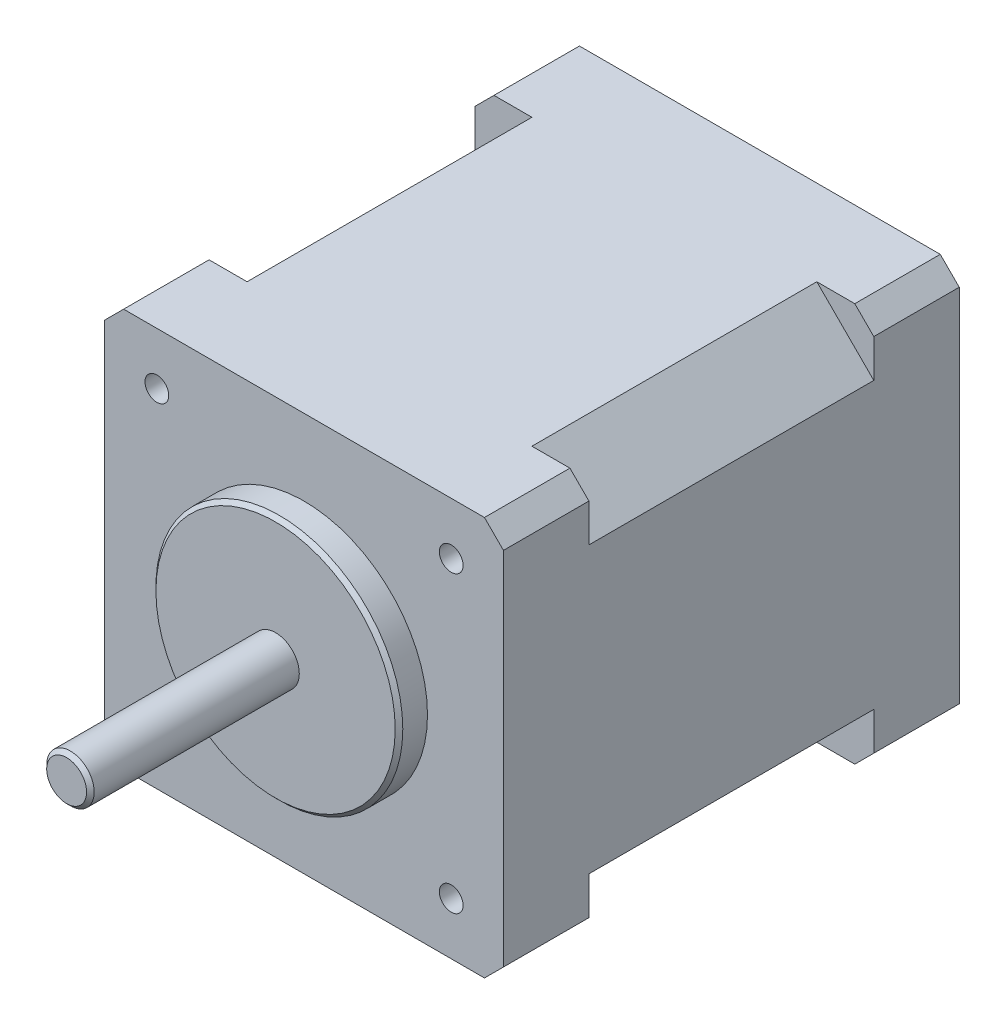
from build123d import *

# Parameters (mm, degrees)
ESQUISSE1_W                               = 42
ESQUISSE1_H                               = 42
BOSS_EXTRU_1_DEPTH                        = 48
CHANFREIN1_SIZE                           = 2
ESQUISSE3_R                               = 13
BOSS_EXTRU_2_DEPTH                        = 3
TROU_POUR_TARAUDAGE_POUR_TROU_TARAUD_M3_D = 2.5
ESQUISSE7_R                               = 2.5
BOSS_EXTRU_3_DEPTH                        = 22
CHANFREIN2_SIZE                           = 0.4
CHANFREIN3_SIZE                           = 0.4
ENL_V_START                               = -9
ENL_V_MAT_EXTRU_1_DEPTH                   = 30


with BuildPart() as part:
    # Esquisse1 → Boss.-Extru.1 (new body)
    with BuildSketch(Plane.XY):
        Rectangle(ESQUISSE1_W, ESQUISSE1_H)
    extrude(amount=BOSS_EXTRU_1_DEPTH)

    # Chanfrein1
    chanfrein1_edges = [part.edges().sort_by_distance(p)[0] for p in [
        (-21, 21, 24),
        (21, 21, 24),
        (21, -21, 24),
        (-21, -21, 24),
    ]]
    chamfer(chanfrein1_edges, length=CHANFREIN1_SIZE)

    # Esquisse3 → Boss.-Extru.2 (add)
    with BuildSketch(Plane.XY.offset(48)):
        Circle(ESQUISSE3_R)
    extrude(amount=BOSS_EXTRU_2_DEPTH)

    # Trou pour taraudage pour trou taraudé M3x0.51 (through all)
    with Locations(Plane.XY.offset(48)):
        with Locations((-15.5, 15.5), (-15.5, -15.5), (15.5, -15.5), (15.5, 15.5)):
            Hole(TROU_POUR_TARAUDAGE_POUR_TROU_TARAUD_M3_D / 2)

    # Esquisse7 → Boss.-Extru.3 (add)
    with BuildSketch(Plane.XY.offset(51)):
        Circle(ESQUISSE7_R)
    extrude(amount=BOSS_EXTRU_3_DEPTH)

    # Chanfrein2
    chanfrein2_edges = [part.edges().sort_by_distance(p)[0] for p in [
        (-2.5, 0, 73),
    ]]
    chamfer(chanfrein2_edges, length=CHANFREIN2_SIZE)

    # Chanfrein3
    chanfrein3_edges = [part.edges().sort_by_distance(p)[0] for p in [
        (-13, 0, 51),
    ]]
    chamfer(chanfrein3_edges, length=CHANFREIN3_SIZE)

    # Esquisse9 → Enlèv. mat.-Extru.1 (cut)
    with BuildSketch(Plane(origin=(0, 0, 0), x_dir=(-1, 0, 0), z_dir=(0, 0, -1)).offset(ENL_V_START)):
        Polygon((-21, 15), (-15, 21), (-21, 21), align=None)
        Polygon((15, 21), (21, 15), (21, 21), align=None)
        Polygon((-21, -15), (-15, -21), (-21, -21), align=None)
        Polygon((15, -21), (21, -15), (21, -21), align=None)
    extrude(amount=-ENL_V_MAT_EXTRU_1_DEPTH, mode=Mode.SUBTRACT)


solid = part.part
